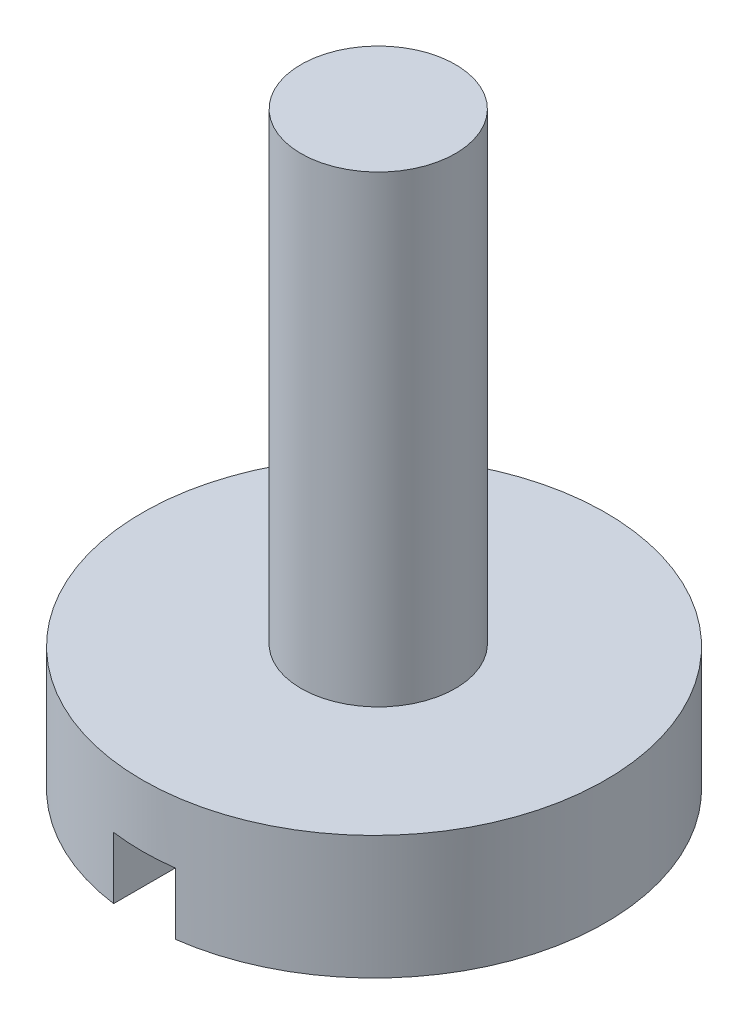
from build123d import *

# Parameters (mm, degrees)
SKETCH_1_R          = 7.5
EXTRUDE_1_DEPTH     = 4
SKETCH_2_R          = 2.5
EXTRUDE_2_DEPTH     = 15
SKETCH_3_W          = 2
SKETCH_3_H          = 15
CUT_EXTRUDE_1_DEPTH = 2


with BuildPart() as part:
    # Эскиз1 → Бобышка-Вытянуть1 (new body)
    with BuildSketch(Plane(origin=(0, 0, 0), x_dir=(1, 0, 0), z_dir=(0, 1, 0))):
        Circle(SKETCH_1_R)
    extrude(amount=EXTRUDE_1_DEPTH)

    # Эскиз2 → Бобышка-Вытянуть2 (add)
    with BuildSketch(Plane(origin=(0, 4, 0), x_dir=(1, 0, 0), z_dir=(0, 1, 0))):
        with Locations((0, 0.136309696)):
            Circle(SKETCH_2_R)
    extrude(amount=EXTRUDE_2_DEPTH)

    # Эскиз3 → Вырез-Вытянуть1 (cut)
    with BuildSketch(Plane.XZ):
        Rectangle(SKETCH_3_W, SKETCH_3_H)
    extrude(amount=-CUT_EXTRUDE_1_DEPTH, mode=Mode.SUBTRACT)


solid = part.part
